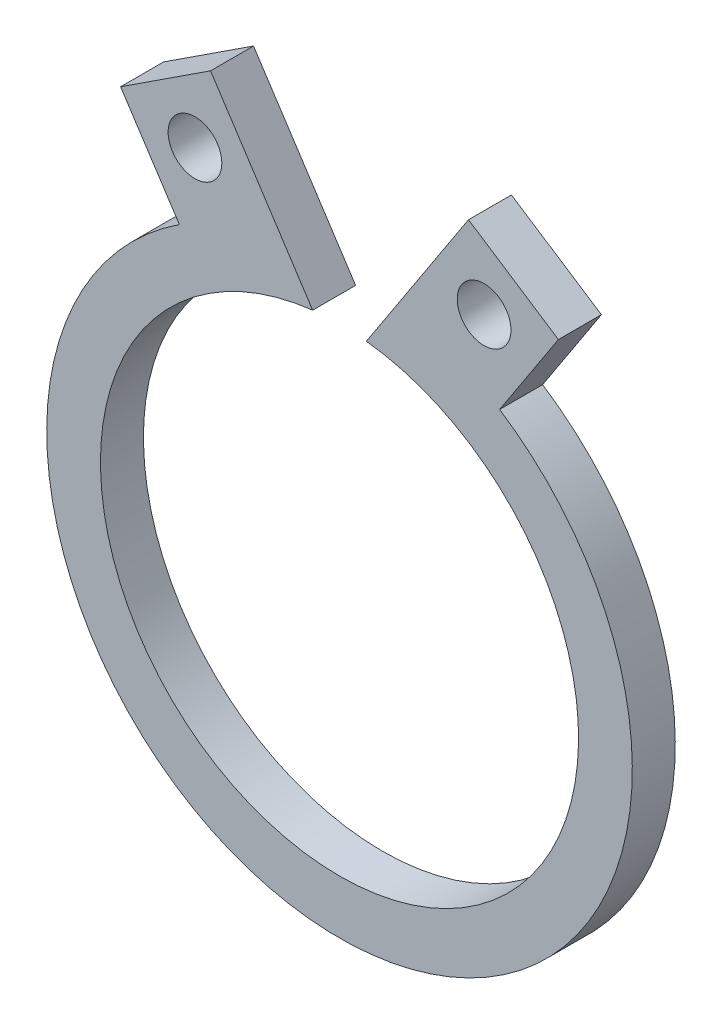
from build123d import *

# Parameters (mm, degrees)
BOSS_EXTRUDE1_DEPTH = 0.8
SKETCH3_R           = 0.5
CUT_EXTRUDE1_DEPTH  = 1.8


with BuildPart() as part:
    # Sketch2 → Boss-Extrude1 (new body)
    with BuildSketch(Plane.XY):
        with BuildLine():
            Line((-4.074883717, 6.236811902), (-2.980955202, 4.562499982))
            ThreePointArc((-2.980955202, 4.562499982), (0, -5.45), (2.980955202, 4.562499982))
            Line((2.980955202, 4.562499982), (4.074883717, 6.236811902))
            Line((4.074883717, 6.236811902), (2.400571797, 7.330740416))
            Line((2.400571797, 7.330740416), (0.5, 4.421820892))
            ThreePointArc((0.5, 4.421820892), (0, -4.45), (-0.5, 4.421820892))
            Line((-0.5, 4.421820892), (-2.400571797, 7.330740416))
            Line((-2.400571797, 7.330740416), (-4.074883717, 6.236811902))
        make_face()
    extrude(amount=BOSS_EXTRUDE1_DEPTH)

    # Sketch3 → Cut-Extrude1 (cut, through all)
    with BuildSketch(Plane.XY.offset(0.8)):
        with Locations((-2.6907635, 5.946620199)):
            Circle(SKETCH3_R)
        with Locations((2.6907635, 5.946620199)):
            Circle(SKETCH3_R)
    extrude(amount=-CUT_EXTRUDE1_DEPTH, mode=Mode.SUBTRACT)


solid = part.part
